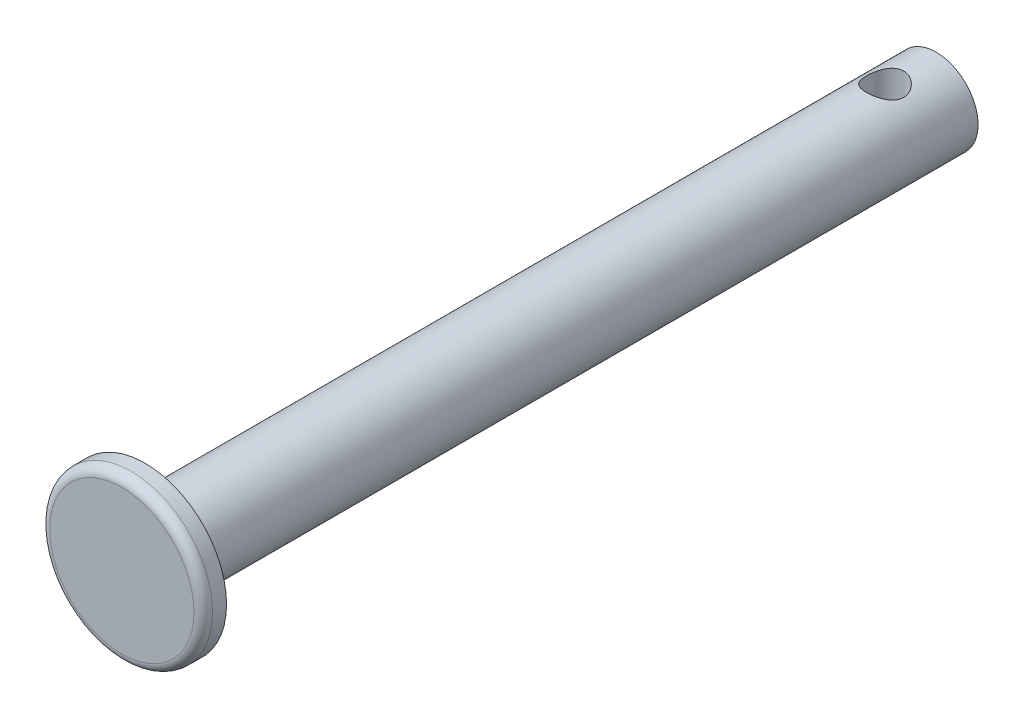
from build123d import *

# Parameters (mm, degrees)
IZIM1_R                     = 17.5
Y_KSEKLIK_EKSTR_ZYON1_DEPTH = 5
RADYUS1_R                   = 2
IZIM2_R                     = 9
Y_KSEKLIK_EKSTR_ZYON2_DEPTH = 170
IZIM3_R                     = 4
KES_EKSTR_ZYON1_DEPTH       = 85


with BuildPart() as part:
    # Çizim1 → Yükseklik-Ekstrüzyon1 (new body)
    with BuildSketch(Plane.XY):
        Circle(IZIM1_R)
    extrude(amount=Y_KSEKLIK_EKSTR_ZYON1_DEPTH)

    # Radyus1
    radyus1_edges = [part.edges().sort_by_distance(p)[0] for p in [
        (-17.5, 0, 5),
    ]]
    fillet(radyus1_edges, radius=RADYUS1_R)

    # Çizim2 → Yükseklik-Ekstrüzyon2 (add)
    with BuildSketch(Plane(origin=(0, 0, 0), x_dir=(-1, 0, 0), z_dir=(0, 0, -1))):
        Circle(IZIM2_R)
    extrude(amount=Y_KSEKLIK_EKSTR_ZYON2_DEPTH)

    # Çizim3 → Kes-Ekstrüzyon1 (cut, symmetric)
    with BuildSketch(Plane(origin=(0, 0, 0), x_dir=(1, 0, 0), z_dir=(0, 1, 0))):
        with Locations((0, 159)):
            Circle(IZIM3_R)
    extrude(amount=KES_EKSTR_ZYON1_DEPTH, both=True, mode=Mode.SUBTRACT)


solid = part.part
